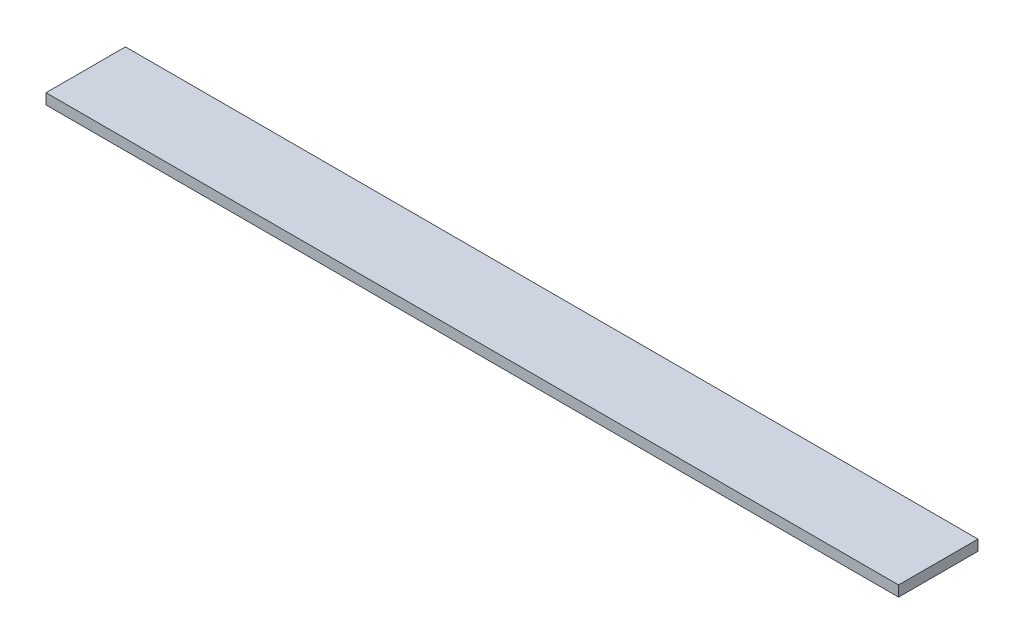
from build123d import *

# Parameters (mm, degrees)
SKETCH_1_W      = 30
SKETCH_1_H      = 4
EXTRUDE_1_DEPTH = 322


with BuildPart() as part:
    # Эскиз1 → Бобышка-Вытянуть1 (new body)
    with BuildSketch(Plane(origin=(0, 0, 0), x_dir=(0, 0, -1), z_dir=(1, 0, 0))):
        Rectangle(SKETCH_1_W, SKETCH_1_H)
    extrude(amount=EXTRUDE_1_DEPTH)


solid = part.part
